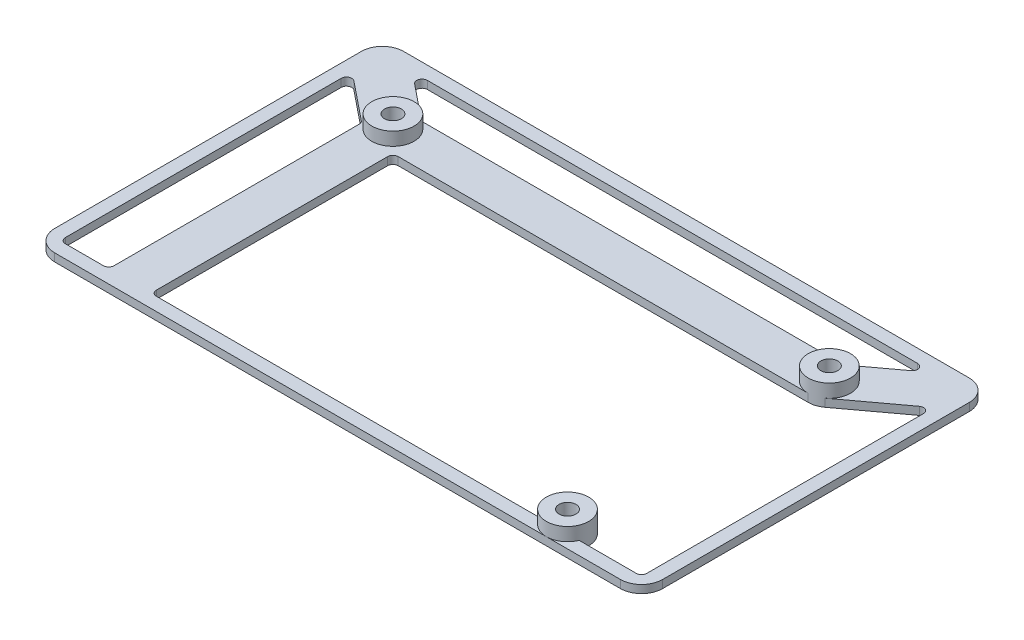
from build123d import *

# Parameters (mm, degrees)
CROQUIS1_R              = 1.6
SALIENTE_EXTRUIR1_DEPTH = 1.5
CROQUIS1_3_R            = 4
CROQUIS1_3_R_2          = 1.6
SALIENTE_EXTRUIR2_DEPTH = 4
CROQUIS2_R              = 1.6
CROQUIS2_W              = 115
CROQUIS2_H              = 66
SALIENTE_EXTRUIR7_DEPTH = 1.5
CORTAR_EXTRUIR1_DEPTH   = 10
REDONDEO1_R             = 1
REDONDEO2_R             = 4


with BuildPart() as part:
    # Croquis1 → Saliente-Extruir1 (new body)
    with BuildSketch(Plane(origin=(0, 0, 0), x_dir=(1, 0, 0), z_dir=(0, 1, 0))):
        with BuildLine():
            ThreePointArc((2.042155055, 3.439418953), (-3.439418964, 2.042155036), (-2.042155017, -3.439418975))
            Line((-2.042155017, -3.439418975), (79.237844983, -51.699418975))
            ThreePointArc((79.237844983, -51.699418975), (83.212910775, -51.76197886), (85.278615677, -48.365226728))
            Line((85.278615677, -48.365226728), (86.548615677, -0.105226728))
            ThreePointArc((86.548615677, -0.105226728), (85.415388884, 2.790975912), (82.55, 4))
            Line((82.55, 4), (1.098018554, 4))
            Line((1.098018554, 4), (2.042155055, 3.439418953))
        make_face()
        Polygon((77.460711282, -41.340348807), (14.571702765, -4), (78.44335204, -4), align=None, mode=Mode.SUBTRACT)
        Circle(CROQUIS1_R, mode=Mode.SUBTRACT)
        with Locations((82.55, 0)):
            Circle(CROQUIS1_R, mode=Mode.SUBTRACT)
        with Locations((81.28, -48.26)):
            Circle(CROQUIS1_R, mode=Mode.SUBTRACT)
    extrude(amount=SALIENTE_EXTRUIR1_DEPTH)

    # Croquis1_3 → Saliente-Extruir2 (add)
    with BuildSketch(Plane(origin=(0, 0, 0), x_dir=(1, 0, 0), z_dir=(0, 1, 0))):
        Circle(CROQUIS1_3_R)
        Circle(CROQUIS1_3_R_2, mode=Mode.SUBTRACT)
        with Locations((82.55, 0)):
            Circle(CROQUIS1_3_R)
        with Locations((82.55, 0)):
            Circle(CROQUIS1_3_R_2, mode=Mode.SUBTRACT)
        with Locations((81.28, -48.26)):
            Circle(CROQUIS1_3_R)
        with Locations((81.28, -48.26)):
            Circle(CROQUIS1_3_R_2, mode=Mode.SUBTRACT)
    extrude(amount=SALIENTE_EXTRUIR2_DEPTH)

    # Croquis2 → Saliente-Extruir7 (add)
    with BuildSketch(Plane.XZ):
        with BuildLine():
            Line((86.548615677, 0.105226728), (85.278615677, 48.365226728))
            ThreePointArc((85.278615677, 48.365226728), (83.212910775, 51.76197886), (79.237844983, 51.699418975))
            Line((79.237844983, 51.699418975), (-2.042155017, 3.439418975))
            ThreePointArc((-2.042155017, 3.439418975), (-3.439418975, -2.042155017), (2.042155017, -3.439418975))
            Line((2.042155017, -3.439418975), (1.098018554, -4))
            Line((1.098018554, -4), (82.55, -4))
            ThreePointArc((82.55, -4), (85.415388884, -2.790975912), (86.548615677, 0.105226728))
        make_face()
        with Locations((81.28, 48.26)):
            Circle(CROQUIS2_R, mode=Mode.SUBTRACT)
        Circle(CROQUIS2_R, mode=Mode.SUBTRACT)
        with Locations((82.55, 0)):
            Circle(CROQUIS2_R, mode=Mode.SUBTRACT)
        Polygon((14.571702765, 4), (77.460711282, 41.340348807), (78.44335204, 4), align=None, mode=Mode.SUBTRACT)
        with Locations((41.78, 19.26)):
            Rectangle(CROQUIS2_W, CROQUIS2_H)
        with BuildLine():
            ThreePointArc((85.278615677, 48.365226728), (83.212910775, 51.76197886), (79.237844983, 51.699418975))
            Line((79.237844983, 51.699418975), (-2.042155017, 3.439418975))
            ThreePointArc((-2.042155017, 3.439418975), (-3.439418975, -2.042155017), (2.042155017, -3.439418975))
            Line((2.042155017, -3.439418975), (1.098018554, -4))
            Line((1.098018554, -4), (82.55, -4))
            ThreePointArc((82.55, -4), (85.415388884, -2.790975912), (86.548615677, 0.105226728))
            Line((86.548615677, 0.105226728), (85.278615677, 48.365226728))
        make_face(mode=Mode.SUBTRACT)
    extrude(amount=-SALIENTE_EXTRUIR7_DEPTH)

    # Croquis4 → Cortar-Extruir1 (cut)
    with BuildSketch(Plane(origin=(0, 1.5, 0), x_dir=(1, 0, 0), z_dir=(0, 1, 0))):
        with BuildLine():
            Line((14.571702765, -4), (4, -4))
            Line((4, -4), (4, -49.76))
            Line((4, -49.76), (77.571900756, -49.76))
            ThreePointArc((77.571900756, -49.76), (80.51593095, -44.33365329), (85.28, -48.26))
            ThreePointArc((85.28, -48.26), (85.20634671, -49.02406905), (84.988099244, -49.76))
            Line((84.988099244, -49.76), (96.78, -49.76))
            Line((96.78, -49.76), (96.78, 5.56))
            Line((96.78, 5.56), (84.93040659, -3.214601759))
            ThreePointArc((84.93040659, -3.214601759), (83.8033142, -3.798579144), (82.55, -4))
            Line((82.55, -4), (78.44335204, -4))
            Line((78.44335204, -4), (77.460711282, -41.340348807))
            Line((77.460711282, -41.340348807), (14.571702765, -4))
        make_face()
        Polygon((91.007430697, 11.24), (-7.57, 11.24), (1.411465404, 4), (81.23022842, 4), align=None)
        Polygon((-13.22, -49.76), (-4, -49.76), (-4, -1.913370522), (-13.22, 5.518913298), align=None)
    extrude(amount=-CORTAR_EXTRUIR1_DEPTH, mode=Mode.SUBTRACT)

    # Redondeo1
    redondeo1_edges = [part.edges().sort_by_distance(p)[0] for p in [
        (4, 0.75, 4),
        (96.78, 0.75, -5.56),
        (96.78, 0.75, 49.76),
        (4, 0.75, 49.76),
        (-4, 0.75, 1.913370522),
        (-4, 0.75, 49.76),
        (-13.22, 0.75, 49.76),
        (-13.22, 0.75, -5.518913298),
        (81.23022842, 0.75, -4),
        (1.411465404, 0.75, -4),
        (-7.57, 0.75, -11.24),
        (91.007430697, 0.75, -11.24),
    ]]
    fillet(redondeo1_edges, radius=REDONDEO1_R)

    # Redondeo2
    redondeo2_edges = [part.edges().sort_by_distance(p)[0] for p in [
        (-15.72, 0.75, 52.26),
        (-15.72, 0.75, -13.74),
        (99.28, 0.75, -13.74),
        (99.28, 0.75, 52.26),
    ]]
    fillet(redondeo2_edges, radius=REDONDEO2_R)


solid = part.part
